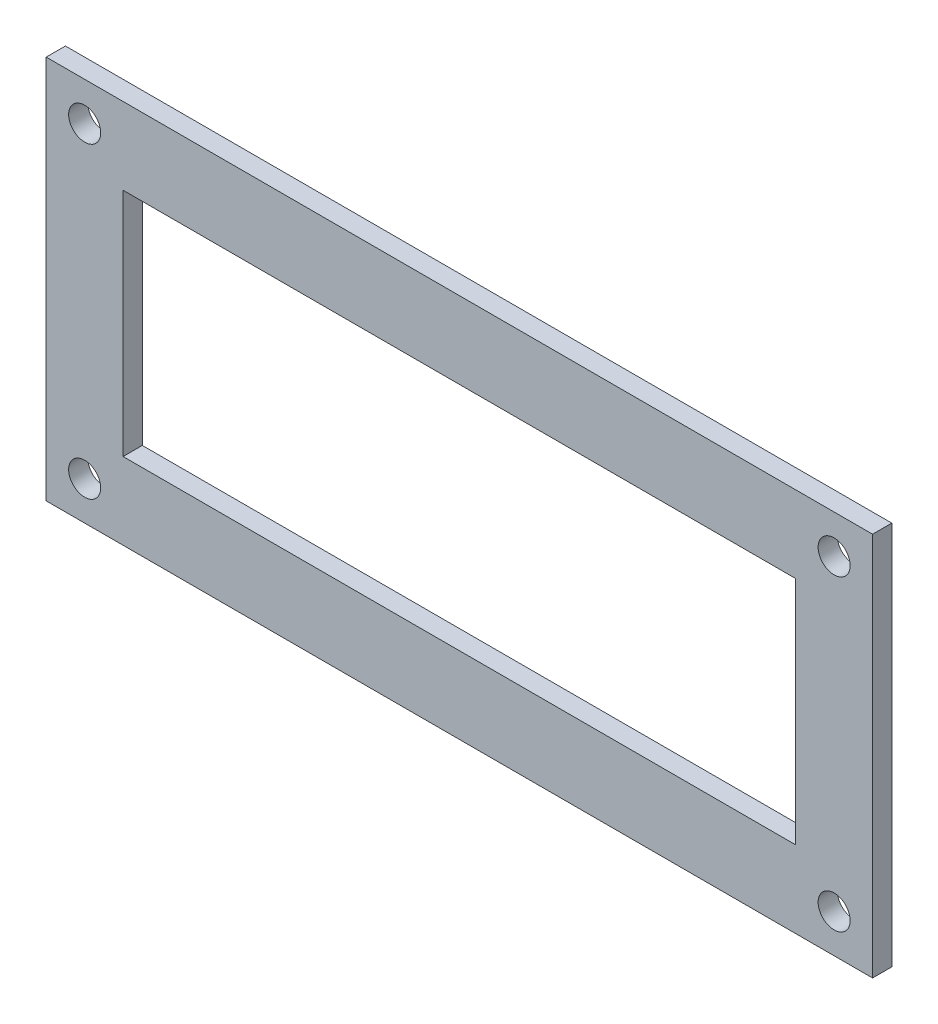
from build123d import *

# Parameters (mm, degrees)
SKETCH1_W           = 129
SKETCH1_H           = 60
SKETCH1_R           = 2.5
SKETCH1_W_2         = 105
SKETCH1_H_2         = 36
BOSS_EXTRUDE1_DEPTH = 3


with BuildPart() as part:
    # Sketch1 → Boss-Extrude1 (new body)
    with BuildSketch(Plane.XY):
        with Locations((64.5, 30)):
            Rectangle(SKETCH1_W, SKETCH1_H)
        with Locations((6, 6)):
            Circle(SKETCH1_R, mode=Mode.SUBTRACT)
        with Locations((6, 54)):
            Circle(SKETCH1_R, mode=Mode.SUBTRACT)
        with Locations((123, 54)):
            Circle(SKETCH1_R, mode=Mode.SUBTRACT)
        with Locations((123, 6)):
            Circle(SKETCH1_R, mode=Mode.SUBTRACT)
        with Locations((64.5, 30)):
            Rectangle(SKETCH1_W_2, SKETCH1_H_2, mode=Mode.SUBTRACT)
    extrude(amount=BOSS_EXTRUDE1_DEPTH)


solid = part.part
